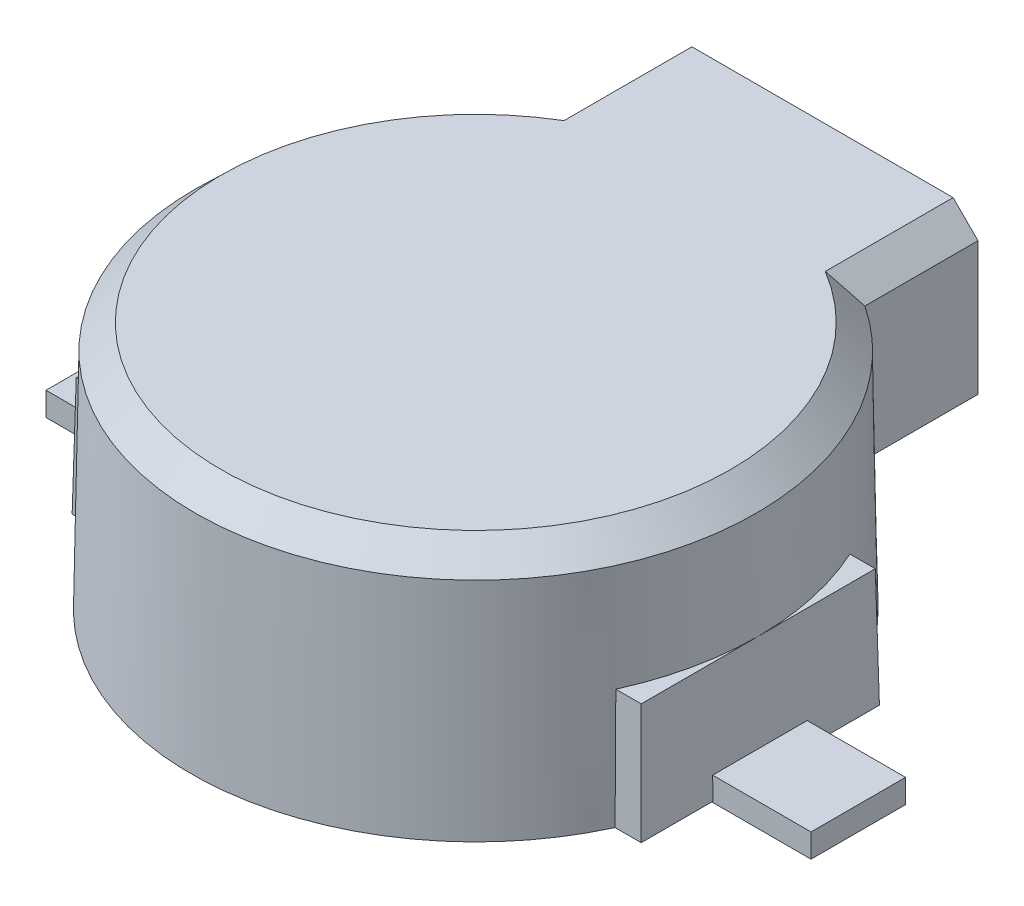
from build123d import *

# Parameters (mm, degrees)
SKETCH1_R             = 4.575
EXTRUDE1_DEPTH        = 4
EXTRUDE1_TAPER        = 1
SKETCH2_W             = 9.15
SKETCH2_H             = 3.83
EXTRUDE2_DEPTH        = 1.9
EXTRUDE2_TAPER        = 1
EXTRUDE3_START        = 1.46
SKETCH3_W             = 5
SKETCH3_H             = 3.66
EXTRUDE3_DEPTH        = 2.54
CUT_EXTRUDE1_START    = -1.025484
SKETCH4_W             = 0.4
SKETCH4_H             = 0.35
CUT_EXTRUDE1_DEPTH    = 1.025484
SKETCH5_W             = 3.5
SKETCH5_H             = 0.7
CUT_EXTRUDE2_DEPTH    = 9.246893526
CHAMFER1_SIZE         = 0.4
CHAMFER1_EDGE_2_SIZE  = 0.4
CHAMFER1_EDGE_3_SIZE  = 0.4
CHAMFER1_EDGE_3_SIZE2 = 0.407168076
SKETCH6_W             = 4.9
SKETCH6_H             = 1.52
EXTRUDE4_DEPTH        = 0.02
EXTRUDE4_DEPTH_BACK   = 0.36


with BuildPart() as part:
    # Sketch1 → Extrude1 (new body)
    with BuildSketch(Plane(origin=(0, 0, 0), x_dir=(1, 0, 0), z_dir=(0, 1, 0))):
        Circle(SKETCH1_R)
    extrude(amount=EXTRUDE1_DEPTH, taper=EXTRUDE1_TAPER)

    # Sketch2 → Extrude2 (add)
    with BuildSketch(Plane(origin=(0, 0, 0), x_dir=(1, 0, 0), z_dir=(0, 1, 0))):
        Rectangle(SKETCH2_W, SKETCH2_H)
    extrude(amount=EXTRUDE2_DEPTH, taper=EXTRUDE2_TAPER)

    # Sketch3 → Extrude3 (add)
    with BuildSketch(Plane(origin=(0, 0, 0), x_dir=(1, 0, 0), z_dir=(0, 1, 0)).offset(EXTRUDE3_START)):
        with Locations((0, 3.745)):
            Rectangle(SKETCH3_W, SKETCH3_H)
    extrude(amount=EXTRUDE3_DEPTH)

    # Sketch4 → Cut-Extrude1 (cut)
    with BuildSketch(Plane(origin=(0, 0, -5.575), x_dir=(-1, 0, 0), z_dir=(0, 0, -1)).offset(CUT_EXTRUDE1_START)):
        with Locations((0, 1.635)):
            Rectangle(SKETCH4_W, SKETCH4_H)
    extrude(amount=CUT_EXTRUDE1_DEPTH, mode=Mode.SUBTRACT)

    # Sketch5 → Cut-Extrude2 (cut, through all)
    with BuildSketch(Plane.XY):
        with Locations((0, 3.15)):
            Rectangle(SKETCH5_W, SKETCH5_H)
    extrude(amount=-CUT_EXTRUDE2_DEPTH, mode=Mode.SUBTRACT)

    # Chamfer1
    chamfer1_edges = [part.edges().sort_by_distance(p)[0] for p in [
        (-2.5, 4, -4.661442668),
    ]]
    chamfer(chamfer1_edges, length=CHAMFER1_SIZE)

    # Chamfer1 edge 2
    chamfer1_edge_2_edges = [part.edges().sort_by_distance(p)[0] for p in [
        (2.5, 4, -4.661442668),
    ]]
    chamfer(chamfer1_edge_2_edges, length=CHAMFER1_EDGE_2_SIZE)

    # Chamfer1 edge 3
    chamfer1_edge_3_edges = [part.edges().sort_by_distance(p)[0] for p in [
        (-2.125287644, 4, 3.972379252),
    ]]
    chamfer1_edge_3_side = [part.faces().sort_by_distance(p)[0] for p in [
        (-4.54008987, 2, 0),
    ]]
    chamfer(chamfer1_edge_3_edges, length=CHAMFER1_EDGE_3_SIZE, length2=CHAMFER1_EDGE_3_SIZE2, reference=chamfer1_edge_3_side[0])

    # Sketch6 → Extrude4 (add, two sides)
    with BuildSketch(Plane.XZ) as extrude4_sk:
        with Locations((3.7, 0)):
            Rectangle(SKETCH6_W, SKETCH6_H)
        with Locations((-3.7, 0)):
            Rectangle(SKETCH6_W, SKETCH6_H)
    extrude(amount=EXTRUDE4_DEPTH)
    extrude(extrude4_sk.sketch, amount=-EXTRUDE4_DEPTH_BACK)


solid = part.part
